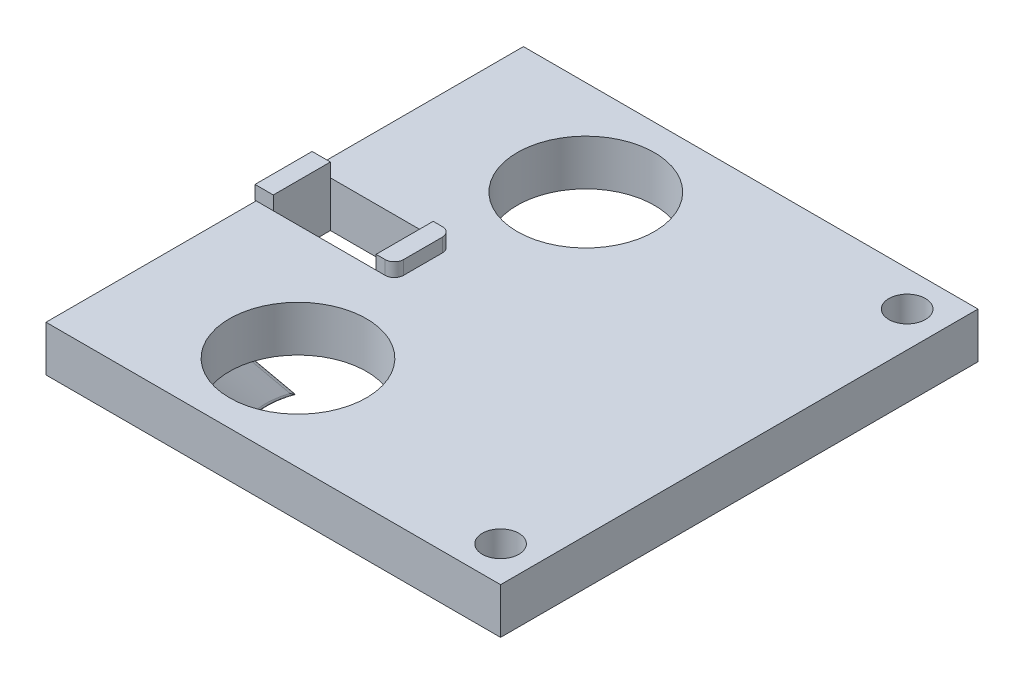
from build123d import *

# Parameters (mm, degrees)
SKETCH2_W           = 100
SKETCH2_H           = 105
BOSS_EXTRUDE1_DEPTH = 10
CUT_EXTRUDE1_REACH  = 75.186
SKETCH5_R           = 15
SKETCH5_R_2         = 5
CUT_EXTRUDE2_REACH  = 75.186
SKETCH6_W           = 22.5
SKETCH6_H           = 12.5
FILLET2_R           = 0.5
CUT_EXTRUDE3_REACH  = 76.42
SKETCH12_R          = 4
SKETCH13_W          = 4
SKETCH13_H          = 12.5
BOSS_EXTRUDE2_DEPTH = 3
FILLET3_R           = 2
CUT_EXTRUDE6_REACH  = 76.42
SKETCH14_W          = 154.448813283
SKETCH14_H          = 123.004866117
SKETCH14_W_2        = 99.5
SKETCH14_H_2        = 104.5


with BuildPart() as part:
    # Sketch2 → Boss-Extrude1 (new body)
    with BuildSketch(Plane(origin=(0, 0, 0), x_dir=(1, 0, 0), z_dir=(0, 1, 0))):
        Rectangle(SKETCH2_W, SKETCH2_H)
    extrude(amount=BOSS_EXTRUDE1_DEPTH)

    # Sketch5 → Cut-Extrude1 (cut, up to next)
    with BuildSketch(Plane.XZ, mode=Mode.PRIVATE) as cut_extrude1_sk1:
        with Locations((-15.347413929, 31.5)):
            Circle(SKETCH5_R)
    cut_extrude1_tool1 = extrude(cut_extrude1_sk1.sketch, amount=-CUT_EXTRUDE1_REACH, mode=Mode.PRIVATE) & part.part
    # Sketch5 → Cut-Extrude1 (cut, up to next)
    with BuildSketch(Plane.XZ, mode=Mode.PRIVATE) as cut_extrude1_sk2:
        with Locations((-40, 0)):
            Circle(SKETCH5_R_2)
    cut_extrude1_tool2 = extrude(cut_extrude1_sk2.sketch, amount=-CUT_EXTRUDE1_REACH, mode=Mode.PRIVATE) & part.part
    cut_extrude1_1 = cut_extrude1_tool1.solids().sort_by_distance((-15.347414, 0, 31.5))[0]
    add(cut_extrude1_1, mode=Mode.SUBTRACT)
    cut_extrude1_2 = cut_extrude1_tool2.solids().sort_by_distance((-40, 0, 0))[0]
    add(cut_extrude1_2, mode=Mode.SUBTRACT)
    cut_extrude1 = cut_extrude1_1 + cut_extrude1_2  # Cut-Extrude1 as one shape, for the pattern or mirror that repeats it

    # Mirror1: Cut-Extrude1 across plane
    add(cut_extrude1.mirror(Plane.XY), mode=Mode.SUBTRACT)

    # Sketch6 → Cut-Extrude2 (cut, up to next)
    with BuildSketch(Plane.XZ, mode=Mode.PRIVATE) as cut_extrude2_sk1:
        with Locations((-34.75, 0)):
            Rectangle(SKETCH6_W, SKETCH6_H)
    cut_extrude2_tool1 = extrude(cut_extrude2_sk1.sketch, amount=-CUT_EXTRUDE2_REACH, mode=Mode.PRIVATE) & part.part
    add(cut_extrude2_tool1.solids().sort_by_distance((-34.75, 0, 0))[0], mode=Mode.SUBTRACT)

    # Sweep1: sweep along a path in Sketch11
    with BuildLine(Plane(origin=(7.914589695, 0, 7.643030426), x_dir=(0, -1, 0), z_dir=(0.7193398003386426, 0, 0.6946583704590061))) as sweep1_path:
        Line((0, -49.687749169), (6.793793585, -43.105226771))
    # Sketch7 → Sweep1 (sweep)
    with BuildSketch(Plane.XZ):
        with BuildLine():
            ThreePointArc((-6.352107338, 43.503518623), (-25.0878405, 42.907194669), (-28.61191488, 24.496214272))
            ThreePointArc((-28.61191488, 24.496214272), (-28.155696018, 46.500017309), (-6.352107338, 43.503518623))
        make_face()
    sweep(path=sweep1_path.line)

    # Fillet2
    fillet2_edges = [part.edges().sort_by_distance(p)[0] for p in [
        (-26.325612738, -3.396896793, 22.128679098),
        (-4.065805196, -3.396896793, 41.135983449),
        (-20.515236217, -6.793793585, 38.172124321),
    ]]
    fillet(fillet2_edges, radius=FILLET2_R)

    # Sketch12 → Cut-Extrude3 (cut, up to next)
    with BuildSketch(Plane(origin=(0, 10, 0), x_dir=(1, 0, 0), z_dir=(0, 1, 0)), mode=Mode.PRIVATE) as cut_extrude3_sk1:
        with Locations((42, 44.5)):
            Circle(SKETCH12_R)
    cut_extrude3_tool1 = extrude(cut_extrude3_sk1.sketch, amount=-CUT_EXTRUDE3_REACH, mode=Mode.PRIVATE) & part.part
    cut_extrude3 = cut_extrude3_tool1.solids().sort_by_distance((42, 10, -44.5))[0]
    add(cut_extrude3, mode=Mode.SUBTRACT)

    # Mirror2: Cut-Extrude3 across plane
    add(cut_extrude3.mirror(Plane.XY), mode=Mode.SUBTRACT)

    # Sketch13 → Boss-Extrude2 (add)
    with BuildSketch(Plane(origin=(0, 10, 0), x_dir=(1, 0, 0), z_dir=(0, 1, 0))):
        with Locations((-48, 0)):
            Rectangle(SKETCH13_W, SKETCH13_H)
        with Locations((-21.5, 0)):
            Rectangle(SKETCH13_W, SKETCH13_H)
    extrude(amount=BOSS_EXTRUDE2_DEPTH)

    # Fillet3
    fillet3_edges = [part.edges().sort_by_distance(p)[0] for p in [
        (-19.5, 11.5, -6.25),
        (-19.5, 11.5, 6.25),
    ]]
    fillet(fillet3_edges, radius=FILLET3_R)

    # Sketch14 → Cut-Extrude6 (cut, up to next)
    with BuildSketch(Plane(origin=(0, 10, 0), x_dir=(1, 0, 0), z_dir=(0, 1, 0)), mode=Mode.PRIVATE) as cut_extrude6_sk1:
        with Locations((-5.953267194, 1.602475316)):
            Rectangle(SKETCH14_W, SKETCH14_H)
        Rectangle(SKETCH14_W_2, SKETCH14_H_2, mode=Mode.SUBTRACT)
    cut_extrude6_tool1 = extrude(cut_extrude6_sk1.sketch, amount=-CUT_EXTRUDE6_REACH, mode=Mode.PRIVATE) & part.part
    add(cut_extrude6_tool1.solids().sort_by_distance((-5.953267, 10, -61.130456))[0], mode=Mode.SUBTRACT)


solid = part.part
